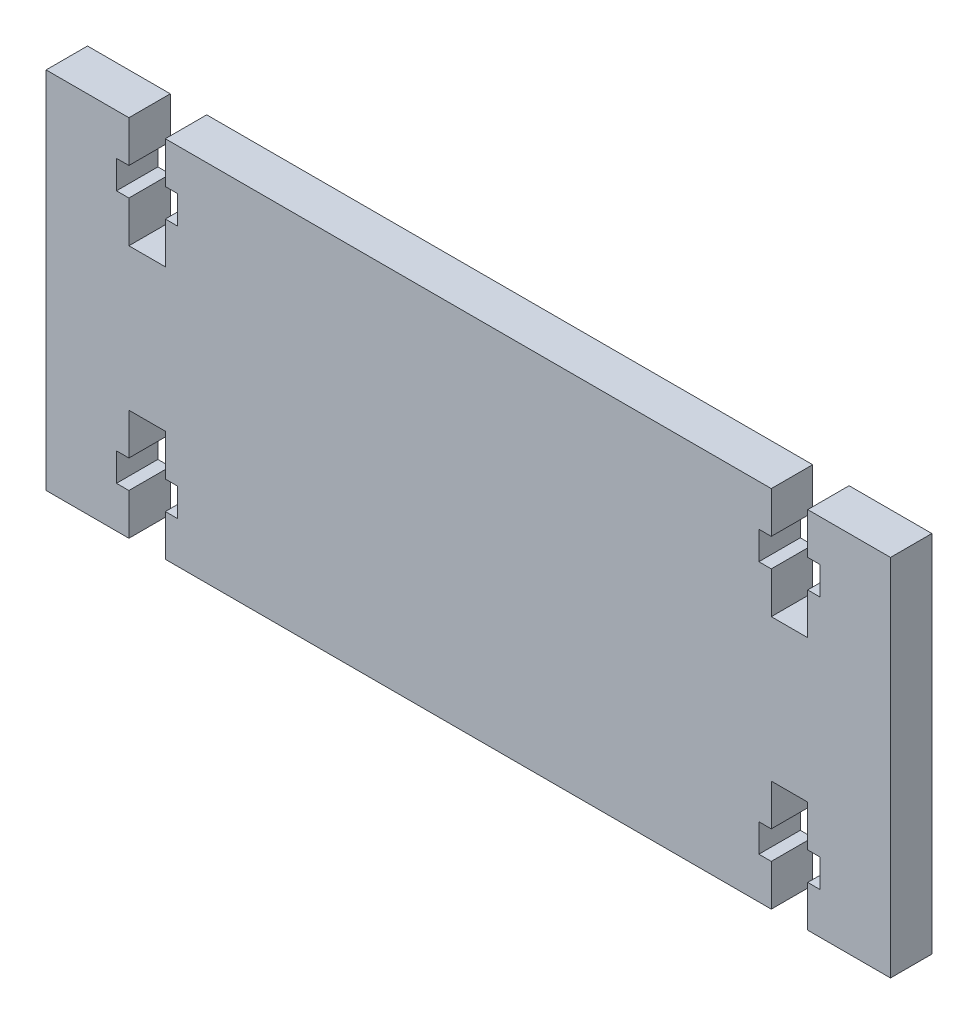
from build123d import *

# Parameters (mm, degrees)
SKETCH1_W           = 102
SKETCH1_H           = 44
BOSS_EXTRUDE1_DEPTH = 5
CUT_EXTRUDE1_DEPTH  = 5


with BuildPart() as part:
    # Sketch1 → Boss-Extrude1 (new body)
    with BuildSketch(Plane.XY):
        Rectangle(SKETCH1_W, SKETCH1_H)
    extrude(amount=BOSS_EXTRUDE1_DEPTH)

    # Sketch3 → Cut-Extrude1 (cut)
    with BuildSketch(Plane.XY.offset(5)):
        Polygon((-36.6, 13.6), (-36.6, 8.6), (-41, 8.6), (-41, 13.6), (-42.5, 13.6), (-42.5, 17), (-41, 17), (-41, 22), (-36.6, 22), (-36.6, 17), (-35.1, 17), (-35.1, 13.6), align=None)
        Polygon((41, 8.6), (41, 13.6), (42.5, 13.6), (42.5, 17), (41, 17), (41, 22), (36.6, 22), (36.6, 17), (35.1, 17), (35.1, 13.6), (36.6, 13.6), (36.6, 8.6), align=None)
        Polygon((36.6, -13.6), (36.6, -8.6), (41, -8.6), (41, -13.6), (42.5, -13.6), (42.5, -17), (41, -17), (41, -22), (36.6, -22), (36.6, -17), (35.1, -17), (35.1, -13.6), align=None)
        Polygon((-41, -8.6), (-41, -13.6), (-42.5, -13.6), (-42.5, -17), (-41, -17), (-41, -22), (-36.6, -22), (-36.6, -17), (-35.1, -17), (-35.1, -13.6), (-36.6, -13.6), (-36.6, -8.6), align=None)
    extrude(amount=-CUT_EXTRUDE1_DEPTH, mode=Mode.SUBTRACT)


solid = part.part
